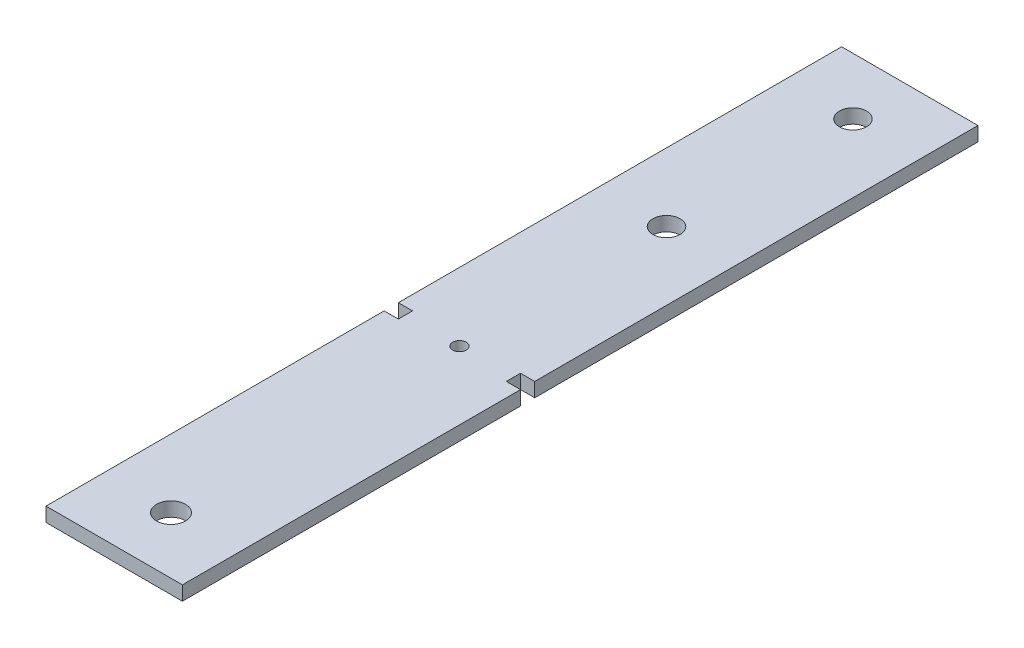
from build123d import *

# Parameters (mm, degrees)
SKETCH1_R           = 1.524
SKETCH1_R_2         = 3.048
SKETCH1_R_3         = 3.2385
BOSS_EXTRUDE1_DEPTH = 3.175


with BuildPart() as part:
    # Sketch1 → Boss-Extrude1 (new body)
    with BuildSketch(Plane(origin=(0, 0, 0), x_dir=(1, 0, 0), z_dir=(0, 1, 0))):
        Polygon((-17.27979029, 88.9), (-17.27979029, -10.16), (-20.45479029, -10.16), (-20.45479029, -13.335), (-17.27979029, -13.335), (-17.27979029, -88.9), (-47.75979029, -88.9), (-47.75979029, -13.335), (-44.58479029, -13.335), (-44.58479029, -10.16), (-47.75979029, -10.16), (-47.75979029, 88.9), align=None)
        with Locations((-32.51979029, -11.7475)):
            Circle(SKETCH1_R, mode=Mode.SUBTRACT)
        with Locations((-32.51979029, 34.529268)):
            Circle(SKETCH1_R_2, mode=Mode.SUBTRACT)
        with Locations((-32.51979029, 76.2)):
            Circle(SKETCH1_R_2, mode=Mode.SUBTRACT)
        with Locations((-32.51979029, -76.2)):
            Circle(SKETCH1_R_3, mode=Mode.SUBTRACT)
    extrude(amount=BOSS_EXTRUDE1_DEPTH)


solid = part.part
